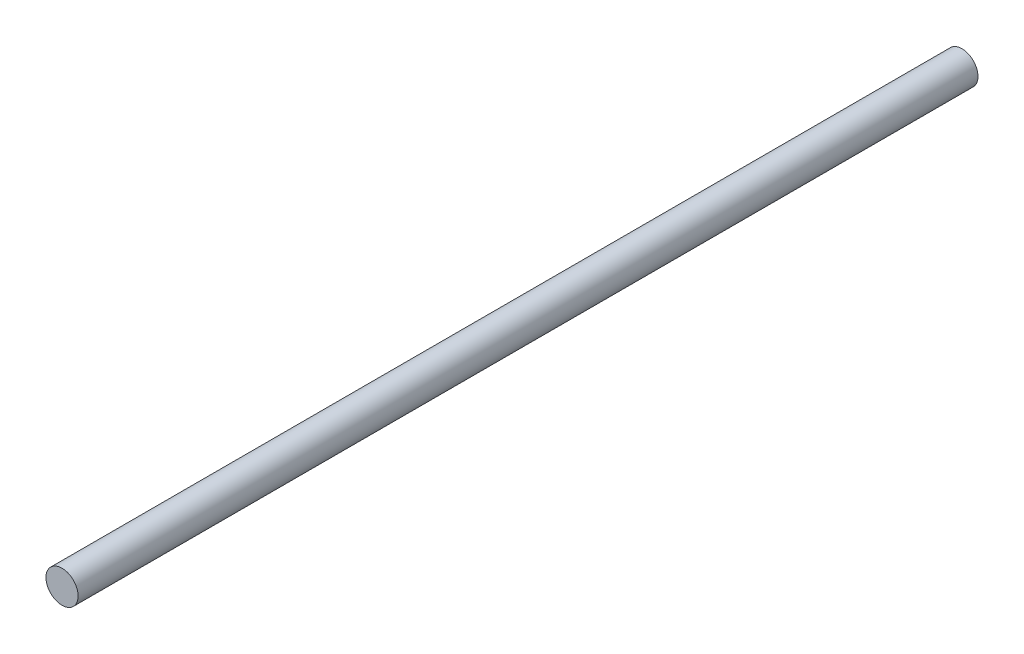
from build123d import *

# Parameters (mm, degrees)
SKETCH1_R           = 2.5
BOSS_EXTRUDE1_DEPTH = 140


with BuildPart() as part:
    # Sketch1 → Boss-Extrude1 (new body)
    with BuildSketch(Plane.XY):
        Circle(SKETCH1_R)
    extrude(amount=BOSS_EXTRUDE1_DEPTH)


solid = part.part
